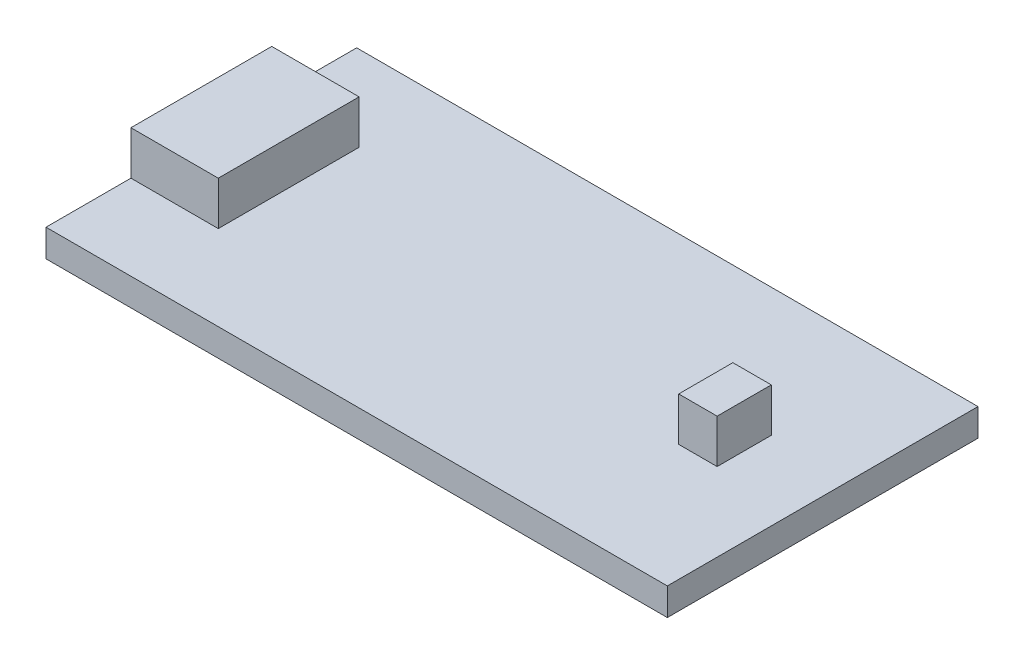
from build123d import *

# Parameters (mm, degrees)
SKETCH1_W      = 35.56
SKETCH1_H      = 17.78
BOARD_DEPTH    = 1.57
SKETCH2_W      = 5
SKETCH2_H      = 8.06
MICROUSB_DEPTH = 2.5
SKETCH3_W      = 2.2
SKETCH3_H      = 3.1
BUTTON_DEPTH   = 2.5


with BuildPart() as part:
    # Sketch1 → Board (new body)
    with BuildSketch(Plane(origin=(0, 0, 0), x_dir=(1, 0, 0), z_dir=(0, 1, 0))):
        Rectangle(SKETCH1_W, SKETCH1_H)
    extrude(amount=BOARD_DEPTH)

    # Sketch2 → MicroUSB (add)
    with BuildSketch(Plane(origin=(0, 1.57, 0), x_dir=(1, 0, 0), z_dir=(0, 1, 0))):
        with Locations((-15.28, 0)):
            Rectangle(SKETCH2_W, SKETCH2_H)
    extrude(amount=MICROUSB_DEPTH)

    # Sketch3 → Button (add)
    with BuildSketch(Plane(origin=(0, 1.57, 0), x_dir=(1, 0, 0), z_dir=(0, 1, 0))):
        with Locations((12.19, 0)):
            Rectangle(SKETCH3_W, SKETCH3_H)
    extrude(amount=BUTTON_DEPTH)


solid = part.part
